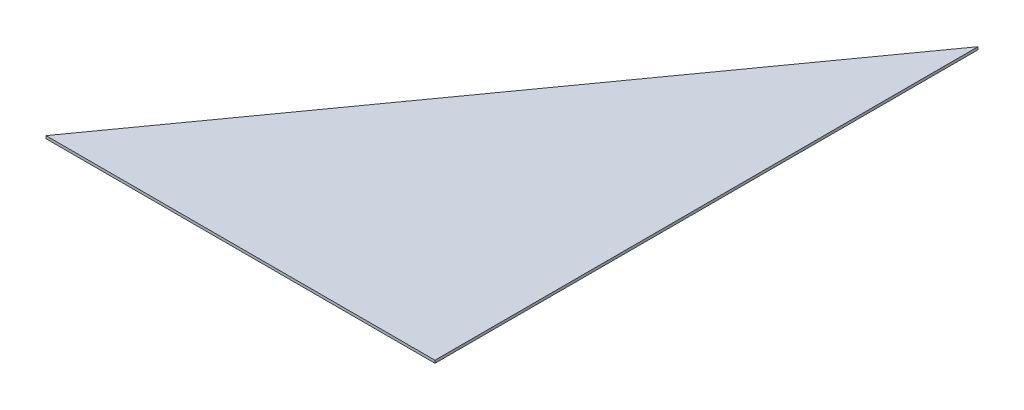
from build123d import *

# Parameters (mm, degrees)
BOSS_EXTRUDE1_DEPTH = 1.5875


with BuildPart() as part:
    # Sketch2 → Boss-Extrude1 (new body)
    with BuildSketch(Plane(origin=(0, 0, 0), x_dir=(1, 0, 0), z_dir=(0, 1, 0))):
        Polygon((0, 0), (228.527880846, 319.024), (228.527880846, 0), align=None)
    extrude(amount=BOSS_EXTRUDE1_DEPTH)


solid = part.part
